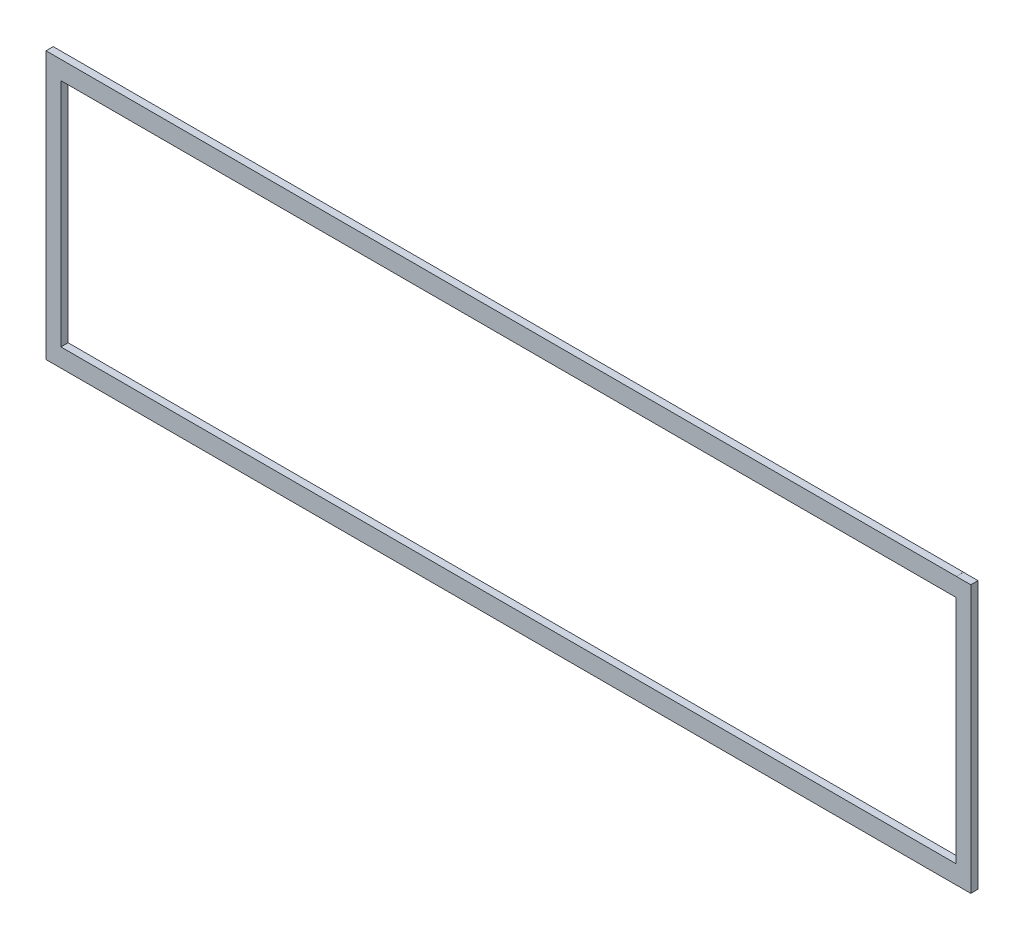
from build123d import *

# Parameters (mm, degrees)
SKETCH1_W           = 393.7
SKETCH1_H           = 101.6
BOSS_EXTRUDE1_DEPTH = 3.175
SKETCH2_W           = 393.4968
SKETCH2_H           = 101.3968
BOSS_EXTRUDE2_DEPTH = 3.175


with BuildPart() as part:
    # Sketch1 → Boss-Extrude1 (new body)
    with BuildSketch(Plane.XY):
        Polygon((0, 0), (400.05, 0), (400.05, 0.0254), (406.4, 0.0254), (406.4, 0), (406.4, 117.36705), (406.4, 117.34165), (400.05, 117.34165), (400.05, 117.36705), (0, 117.36705), align=None)
        with Locations((203.2, 58.683525)):
            Rectangle(SKETCH1_W, SKETCH1_H, mode=Mode.SUBTRACT)
    extrude(amount=BOSS_EXTRUDE1_DEPTH)

    # Sketch2 → Boss-Extrude2 (add)
    with BuildSketch(Plane.XY.offset(3.175)):
        Polygon((400.1516, 117.46865), (-0.1016, 117.46865), (-0.1016, -0.1016), (400.1516, -0.1016), (400.1516, -0.0762), (406.5016, -0.0762), (406.5016, 117.44325), (400.1516, 117.44325), align=None)
        with Locations((203.2, 58.683525)):
            Rectangle(SKETCH2_W, SKETCH2_H, mode=Mode.SUBTRACT)
    extrude(amount=-BOSS_EXTRUDE2_DEPTH)


solid = part.part
